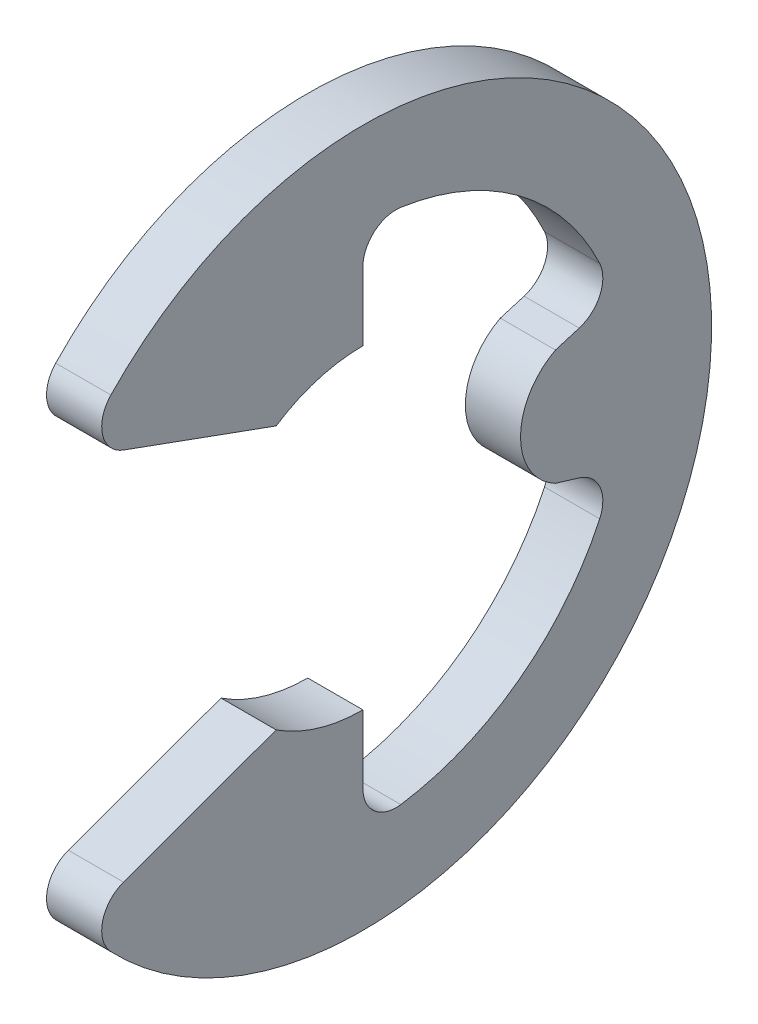
from build123d import *

# Parameters (mm, degrees)
EXTRUDE1_DEPTH          = 0.35
FILLET1_R               = 0.42
CUT_EXTRUDE1_DEPTH      = 7.267675008
CUT_EXTRUDE1_DEPTH_BACK = 7.267675008


with BuildPart() as part:
    # Sketch1 → Extrude1 (new, symmetric)
    with BuildSketch(Plane(origin=(0, 0, 0), x_dir=(0, 0, -1), z_dir=(1, 0, 0))):
        with BuildLine():
            Line((-3.59727207, -2.576869934), (-1.100499886, -1.67))
            ThreePointArc((-1.100499886, -1.67), (-0.574456265, -1.915724406), (0, -2))
            Line((0, -2), (0, -3.316129032))
            ThreePointArc((0, -3.316129032), (1.979664969, -2.660383125), (3.17639466, -0.952485548))
            Line((3.17639466, -0.952485548), (1.915724406, -0.574456265))
            ThreePointArc((1.915724406, -0.574456265), (2, 0), (1.915724406, 0.574456265))
            Line((1.915724406, 0.574456265), (3.17639466, 0.952485548))
            ThreePointArc((3.17639466, 0.952485548), (1.979664969, 2.660383125), (0, 3.316129032))
            Line((0, 3.316129032), (0, 2))
            ThreePointArc((0, 2), (-0.574456265, 1.915724406), (-1.100499886, 1.67))
            Line((-1.100499886, 1.67), (-3.59727207, 2.576869934))
            ThreePointArc((-3.59727207, 2.576869934), (4.425, 0), (-3.59727207, -2.576869934))
        make_face()
    extrude(amount=EXTRUDE1_DEPTH, both=True)

    # Fillet1
    fillet1_edges = [part.edges().sort_by_distance(p)[0] for p in [
        (0, -3.316129032, 0),
        (0, 3.316129032, 0),
        (0, -2.576869934, 3.59727207),
        (0, 2.576869934, 3.59727207),
        (0, -0.952485548, -3.17639466),
        (0, 0.952485548, -3.17639466),
    ]]
    fillet(fillet1_edges, radius=FILLET1_R)

    # Sketch4 → Cut-Extrude1 (cut, two sides: drawn at the far end of the back side and taken through both)
    with BuildSketch(Plane(origin=(0, 0, 0), x_dir=(0, 0, -1), z_dir=(1, 0, 0)).offset(-CUT_EXTRUDE1_DEPTH_BACK)):
        with BuildLine():
            ThreePointArc((0.480908888, 3.281072751), (0.145392765, 3.183303361), (0, 2.865512759))
            Line((0, 2.865512759), (0, -2.865512759))
            ThreePointArc((0, -2.865512759), (0.145392765, -3.183303361), (0.480908888, -3.281072751))
            ThreePointArc((0.480908888, -3.281072751), (1.979664969, -2.660383125), (3.004685012, -1.403060846))
            ThreePointArc((3.004685012, -1.403060846), (3.007405078, -1.053600513), (2.744766364, -0.823055878))
            ThreePointArc((2.744766364, -0.823055878), (2, 0), (2.744766364, 0.823055878))
            ThreePointArc((2.744766364, 0.823055878), (3.007405078, 1.053600513), (3.004685012, 1.403060846))
            ThreePointArc((3.004685012, 1.403060846), (1.979664969, 2.660383125), (0.480908888, 3.281072751))
        make_face()
    extrude(amount=CUT_EXTRUDE1_DEPTH + CUT_EXTRUDE1_DEPTH_BACK, mode=Mode.SUBTRACT)


solid = part.part
